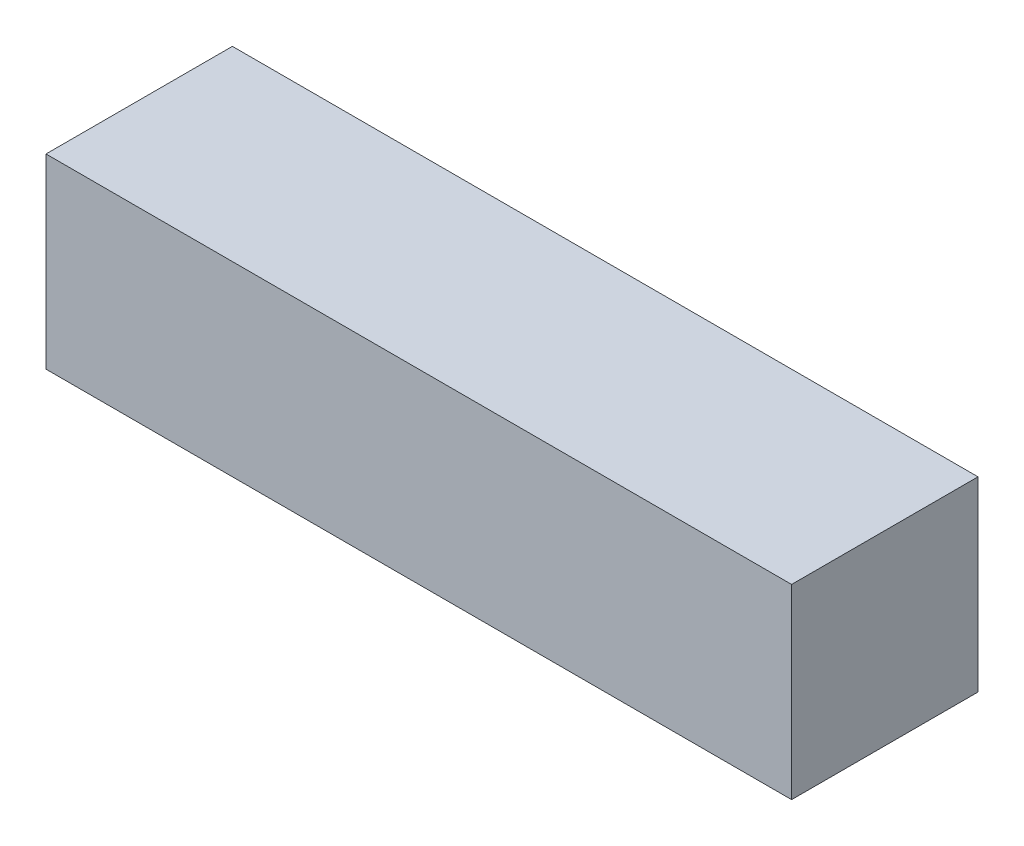
from build123d import *

# Parameters (mm, degrees)
CROQUIS1_W              = 24
CROQUIS1_H              = 6
SALIENTE_EXTRUIR1_DEPTH = 6


with BuildPart() as part:
    # Croquis1 → Saliente-Extruir1 (new body)
    with BuildSketch(Plane(origin=(0, 0, 0), x_dir=(1, 0, 0), z_dir=(0, 1, 0))):
        Rectangle(CROQUIS1_W, CROQUIS1_H)
    extrude(amount=SALIENTE_EXTRUIR1_DEPTH)


solid = part.part
